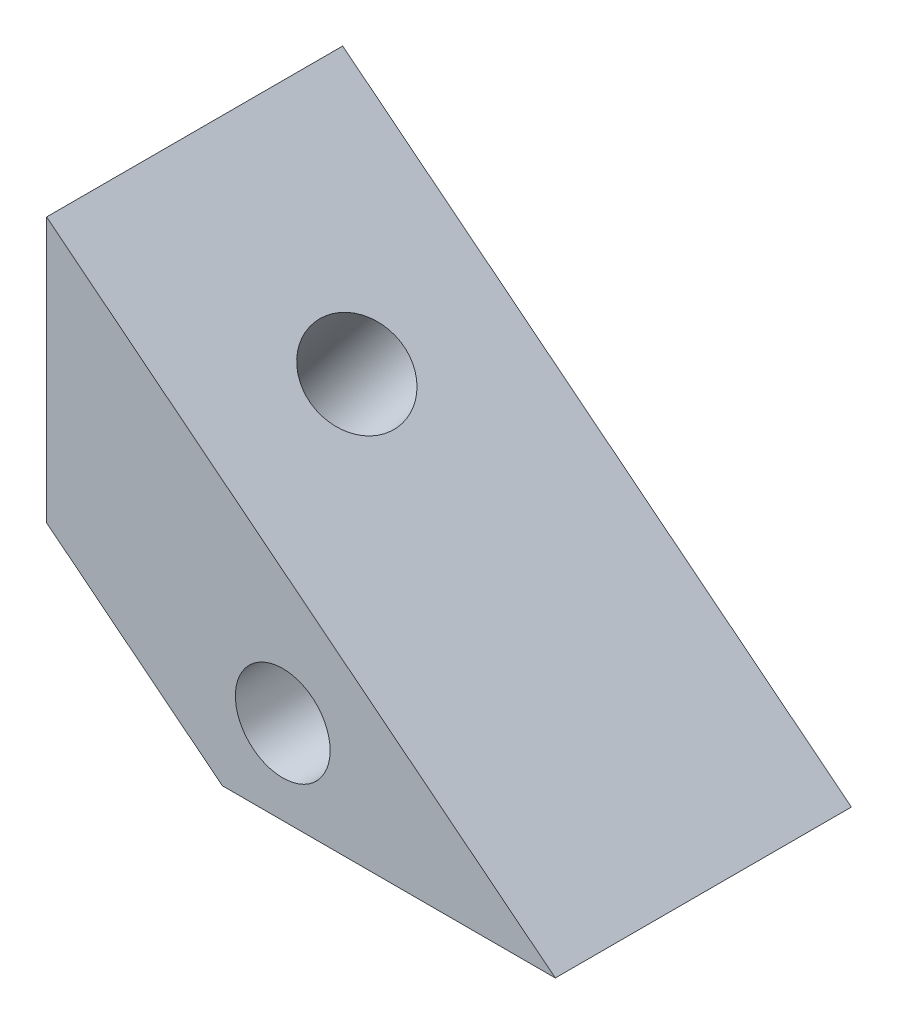
from build123d import *

# Parameters (mm, degrees)
CROQUIS1_R              = 1.6
SALIENTE_EXTRUIR1_DEPTH = 10
CORTAR_EXTRUIR1_DEPTH   = 5.5
CORTAR_EXTRUIR2_REACH   = 12.696
CROQUIS3_R              = 1.6
CORTAR_EXTRUIR3_DEPTH   = 2.5


with BuildPart() as part:
    # Croquis1 → Saliente-Extruir1 (new body)
    with BuildSketch(Plane.XY):
        Polygon((17.180905327, 0), (5.936351089, 0), (0, 4.722097457), (0, 13.666629237), align=None)
        with Locations((7.975771065, 2.85)):
            Circle(CROQUIS1_R, mode=Mode.SUBTRACT)
    extrude(amount=SALIENTE_EXTRUIR1_DEPTH)

    # Croquis2 → Cortar-Extruir1 (cut)
    with BuildSketch(Plane.XY.offset(10)):
        Polygon((6.330322798, 0), (9.621219332, 0), (11.2666676, 2.85), (9.621219332, 5.7), (6.330322798, 5.7), (4.684874531, 2.85), align=None)
    extrude(amount=-CORTAR_EXTRUIR1_DEPTH, mode=Mode.SUBTRACT)

    # Croquis3 → Cortar-Extruir2 (cut, up to next)
    with BuildSketch(Plane(origin=(6.658212283, 8.370324012, 0), x_dir=(0.782601054, -0.622523566, 0), z_dir=(0.622523566, 0.782601054, 0)), mode=Mode.PRIVATE) as cortar_extruir2_sk1:
        with Locations((-1.507798766, -5)):
            Circle(CROQUIS3_R)
    cortar_extruir2_tool1 = extrude(cortar_extruir2_sk1.sketch, amount=-CORTAR_EXTRUIR2_REACH, mode=Mode.PRIVATE) & part.part
    add(cortar_extruir2_tool1.solids().sort_by_distance((5.478207, 9.308964, 5))[0], mode=Mode.SUBTRACT)

    # Croquis4 → Cortar-Extruir3 (cut)
    with BuildSketch(Plane(origin=(2.300547322, 2.892116633, 0), x_dir=(0.782601054, -0.622523566, 0), z_dir=(-0.622523566, -0.782601054, 0))):
        Polygon((1.783097769, 5), (0.137649502, 7.85), (-3.153247033, 7.85), (-4.7986953, 5), (-3.153247033, 2.15), (0.137649502, 2.15), align=None)
    extrude(amount=-CORTAR_EXTRUIR3_DEPTH, mode=Mode.SUBTRACT)


with BuildPart() as body_2:
    # Simetría1: mirrored copy
    add(part.part.mirror(Plane(origin=(0, 13.666629237, 0), x_dir=(1, 0, 0), z_dir=(0, 0, 1))))


solid = body_2.part
